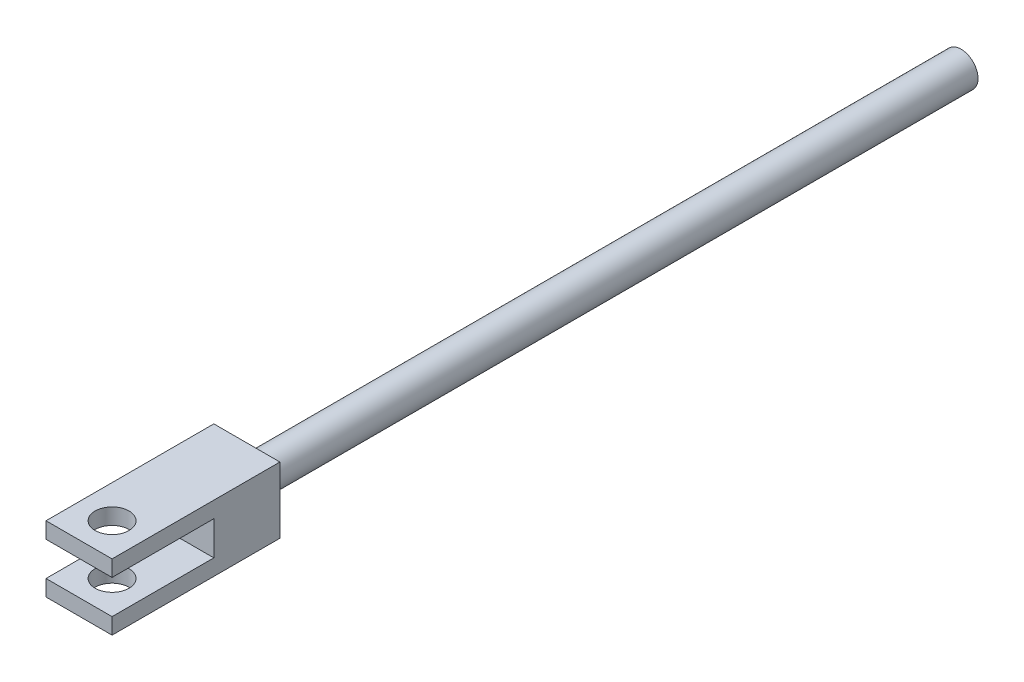
from build123d import *

# Parameters (mm, degrees)
SKETCH1_W           = 9.398
SKETCH1_H           = 9.398
BOSS_EXTRUDE1_DEPTH = 23.876
SKETCH2_W           = 14.478
SKETCH2_H           = 4.826
CUT_EXTRUDE1_DEPTH  = 10.398
SKETCH3_R           = 2.413
CUT_EXTRUDE2_DEPTH  = 10.398
SKETCH4_R           = 2.413
BOSS_EXTRUDE2_DEPTH = 101.6


with BuildPart() as part:
    # Sketch1 → Boss-Extrude1 (new body)
    with BuildSketch(Plane.XY):
        Rectangle(SKETCH1_W, SKETCH1_H)
    extrude(amount=BOSS_EXTRUDE1_DEPTH)

    # Sketch2 → Cut-Extrude1 (cut, through all)
    with BuildSketch(Plane(origin=(4.699, 0, 0), x_dir=(0, 0, -1), z_dir=(1, 0, 0))):
        with Locations((-16.637, 0)):
            Rectangle(SKETCH2_W, SKETCH2_H)
    extrude(amount=-CUT_EXTRUDE1_DEPTH, mode=Mode.SUBTRACT)

    # Sketch3 → Cut-Extrude2 (cut, through all)
    with BuildSketch(Plane(origin=(0, 4.699, 0), x_dir=(1, 0, 0), z_dir=(0, 1, 0))):
        with Locations((0, -19.177)):
            Circle(SKETCH3_R)
    extrude(amount=-CUT_EXTRUDE2_DEPTH, mode=Mode.SUBTRACT)

    # Sketch4 → Boss-Extrude2 (add)
    with BuildSketch(Plane(origin=(0, 0, 0), x_dir=(-1, 0, 0), z_dir=(0, 0, -1))):
        Circle(SKETCH4_R)
    extrude(amount=BOSS_EXTRUDE2_DEPTH)


solid = part.part
